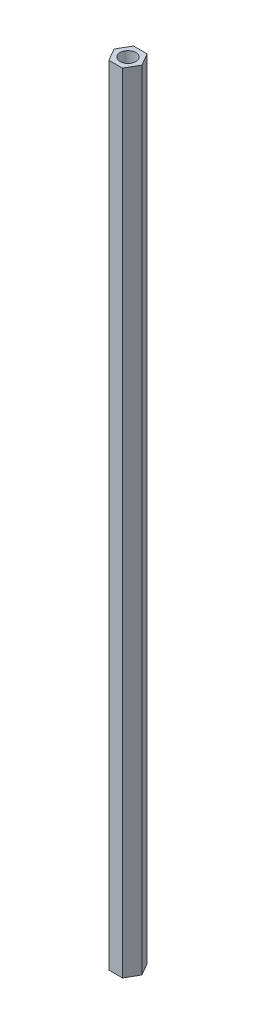
from build123d import *

# Parameters (mm, degrees)
SKETCH_1_R      = 1.5
EXTRUDE_1_DEPTH = 150


with BuildPart() as part:
    # 草图1 → 凸台-拉伸1 (new body)
    with BuildSketch(Plane(origin=(0, 0, 0), x_dir=(1, 0, 0), z_dir=(0, 1, 0))):
        Polygon((1.293226867, 2.35), (-1.293226867, 2.35), (-2.65, 0), (-1.293226867, -2.35), (1.293226867, -2.35), (2.65, 0), align=None)
        Circle(SKETCH_1_R, mode=Mode.SUBTRACT)
    extrude(amount=EXTRUDE_1_DEPTH)


solid = part.part
